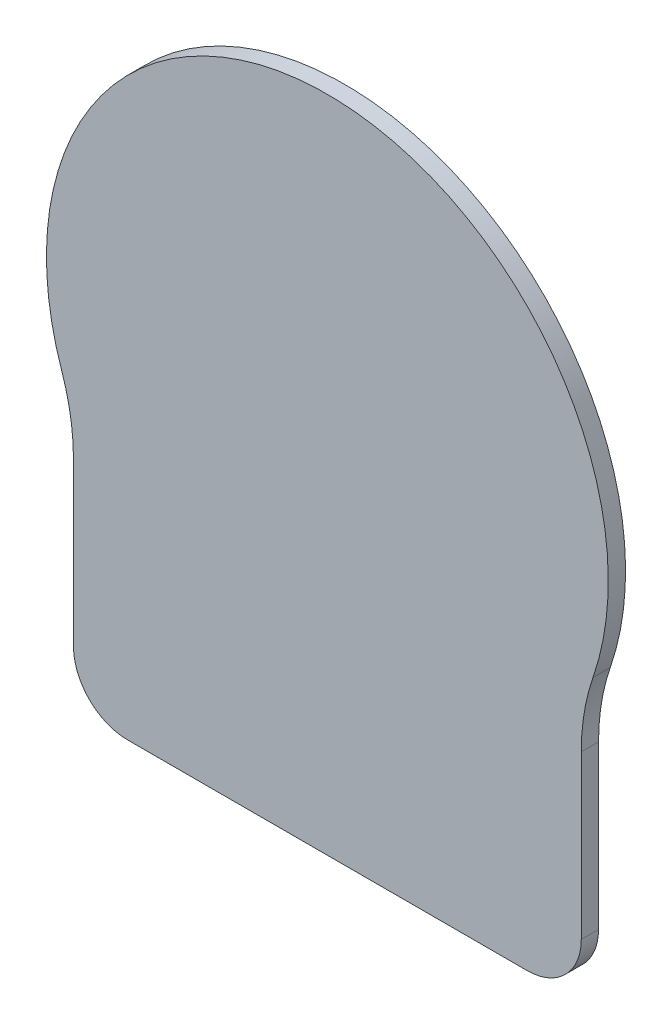
from build123d import *

# Parameters (mm, degrees)
BOSS_EXTRUDE1_DEPTH = 1.6


with BuildPart() as part:
    # Sketch1 → Boss-Extrude1 (new body)
    with BuildSketch(Plane.XY):
        with BuildLine():
            Line((-23.5, -14.958275302), (-23.5, -30))
            ThreePointArc((-23.5, -30), (-22.035533906, -33.535533906), (-18.5, -35))
            Line((-18.5, -35), (18.5, -35))
            ThreePointArc((18.5, -35), (22.035533906, -33.535533906), (23.5, -30))
            Line((23.5, -30), (23.5, -14.958275302))
            ThreePointArc((23.5, -14.958275302), (23.773610701, -11.661372935), (24.586956522, -8.454677344))
            ThreePointArc((24.586956522, -8.454677344), (0, 26), (-24.586956522, -8.454677344))
            ThreePointArc((-24.586956522, -8.454677344), (-23.773610701, -11.661372935), (-23.5, -14.958275302))
        make_face()
    extrude(amount=BOSS_EXTRUDE1_DEPTH)


solid = part.part
